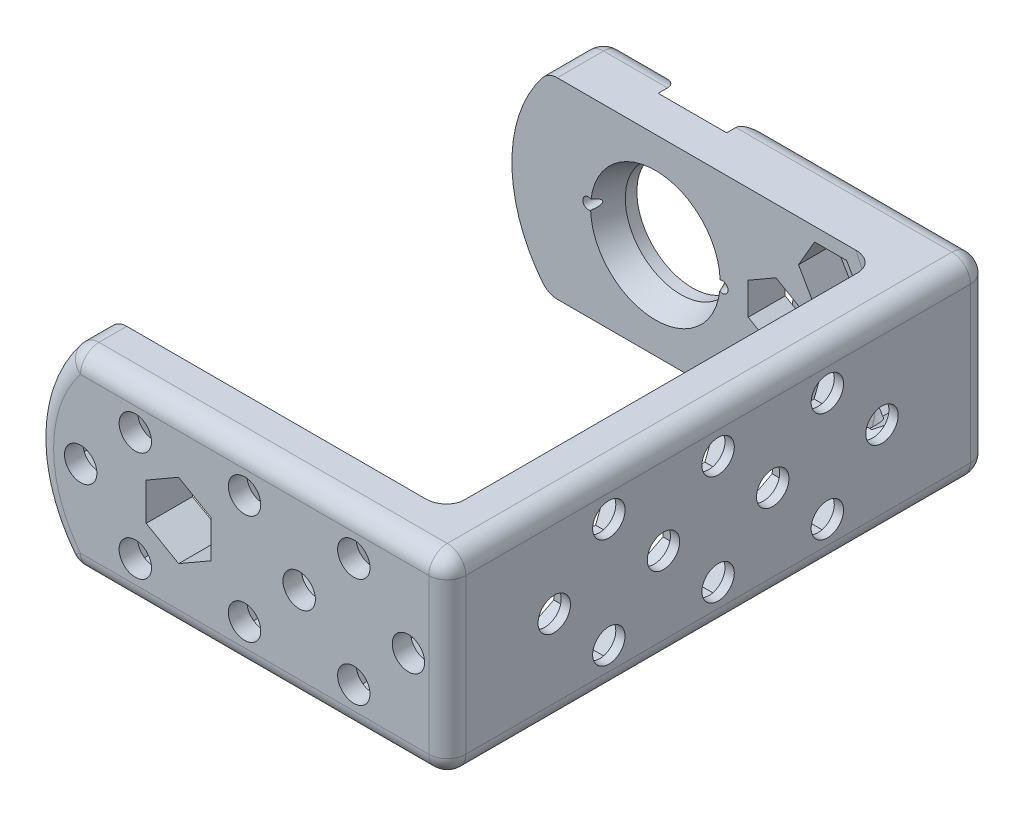
from build123d import *

# Parameters (mm, degrees)
SKETCH_1_R               = 6
EXTRUDE_1_DEPTH          = 5
EXTRUDE_4_DEPTH          = 2
EXTRUDE_START            = 5
EXTRUDE_5_DEPTH          = 46.5
EXTRUDE_7_DEPTH          = 5
FILLET_1_R               = 2
SKETCH_3_R               = 0.6
CUT_EXTRUDE_1_DEPTH      = 5
SKETCH_4_R               = 1.75
CUT_EXTRUDE_2_DEPTH      = 73.677365959
CUT_EXTRUDE_START        = -6
SKETCH_4_5_R             = 1.75
CUT_EXTRUDE_4_DEPTH      = 5
SKETCH_5_R               = 1.75
CUT_EXTRUDE_5_DEPTH      = 5
CUT_EXTRUDE_START_2      = -5
SKETCH_5_4_R             = 1.75
CUT_EXTRUDE_6_DEPTH      = 3
CUT_EXTRUDE_6_DEPTH_BACK = 3
SKETCH_6_R               = 1.75
CUT_EXTRUDE_7_DEPTH      = 7
CUT_EXTRUDE_START_3      = -7
CUT_EXTRUDE_8_DEPTH      = 4
CUT_EXTRUDE_8_DEPTH_BACK = 3
CUT_EXTRUDE_START_4      = -4
SKETCH_4_7_R             = 1.75
CUT_EXTRUDE_9_DEPTH      = 3
SKETCH_7_R               = 7
CUT_EXTRUDE_10_DEPTH     = 3
CUT_EXTRUDE_10_DRAFT     = -20
SKETCH_1_9_R             = 6
CUT_EXTRUDE_11_DEPTH     = 1


with BuildPart() as part:
    # Эскиз1 → Бобышка-Вытянуть1 (new body)
    with BuildSketch(Plane.XY):
        with BuildLine():
            Line((-10.599372336, -10.360819702), (27.024183719, -10.360819702))
            ThreePointArc((27.024183719, -10.360819702), (28.438397281, -9.775033264), (29.024183719, -8.360819702))
            Line((29.024183719, -8.360819702), (29.024183719, 8.360819702))
            ThreePointArc((29.024183719, 8.360819702), (28.438397281, 9.775033264), (27.024183719, 10.360819702))
            Line((27.024183719, 10.360819702), (-10.599372336, 10.360819702))
            ThreePointArc((-10.599372336, 10.360819702), (-11.471931815, 10.160441872), (-12.169649719, 9.599459658))
            ThreePointArc((-12.169649719, 9.599459658), (-15.5, 0), (-12.169649719, -9.599459658))
            ThreePointArc((-12.169649719, -9.599459658), (-11.471931815, -10.160441872), (-10.599372336, -10.360819702))
        make_face()
        Circle(SKETCH_1_R, mode=Mode.SUBTRACT)
    extrude(amount=EXTRUDE_1_DEPTH)

    # Эскиз1<5> → Бобышка-Вытянуть4 (add)
    with BuildSketch(Plane.XY):
        with BuildLine():
            Line((-10.599372336, -10.360819702), (-3.695052788, -10.360819702))
            ThreePointArc((-3.695052788, -10.360819702), (-11, 0), (-3.695052788, 10.360819702))
            Line((-3.695052788, 10.360819702), (-10.599372336, 10.360819702))
            ThreePointArc((-10.599372336, 10.360819702), (-11.471931815, 10.160441872), (-12.169649719, 9.599459658))
            ThreePointArc((-12.169649719, 9.599459658), (-15.5, 0), (-12.169649719, -9.599459658))
            ThreePointArc((-12.169649719, -9.599459658), (-11.471931815, -10.160441872), (-10.599372336, -10.360819702))
        make_face()
        with BuildLine():
            Line((3.695052788, -10.360819702), (23.872820389, -10.360819702))
            ThreePointArc((23.872820389, -10.360819702), (26.024183719, 0), (23.872820389, 10.360819702))
            Line((23.872820389, 10.360819702), (3.695052788, 10.360819702))
            ThreePointArc((3.695052788, 10.360819702), (8.990149628, 6.338549492), (11, 0))
            ThreePointArc((11, 0), (8.990149628, -6.338549492), (3.695052788, -10.360819702))
        make_face()
        with BuildLine():
            ThreePointArc((23.872820389, 10.360819702), (26.024183719, 0), (23.872820389, -10.360819702))
            Line((23.872820389, -10.360819702), (27.024183719, -10.360819702))
            ThreePointArc((27.024183719, -10.360819702), (28.438397281, -9.775033264), (29.024183719, -8.360819702))
            Line((29.024183719, -8.360819702), (29.024183719, 8.360819702))
            ThreePointArc((29.024183719, 8.360819702), (28.438397281, 9.775033264), (27.024183719, 10.360819702))
            Line((27.024183719, 10.360819702), (23.872820389, 10.360819702))
        make_face()
    extrude(amount=-EXTRUDE_4_DEPTH)

    # Эскиз1<7> → Бобышка-Вытянуть5 (add)
    with BuildSketch(Plane.XY.offset(EXTRUDE_START)):
        with BuildLine():
            ThreePointArc((23.872820389, 10.360819702), (26.024183719, 0), (23.872820389, -10.360819702))
            Line((23.872820389, -10.360819702), (27.024183719, -10.360819702))
            ThreePointArc((27.024183719, -10.360819702), (28.438397281, -9.775033264), (29.024183719, -8.360819702))
            Line((29.024183719, -8.360819702), (29.024183719, 8.360819702))
            ThreePointArc((29.024183719, 8.360819702), (28.438397281, 9.775033264), (27.024183719, 10.360819702))
            Line((27.024183719, 10.360819702), (23.872820389, 10.360819702))
        make_face()
    extrude(amount=EXTRUDE_5_DEPTH)

    # Эскиз2 → Бобышка-Вытянуть7 (add)
    with BuildSketch(Plane.XY.offset(51.5)):
        with BuildLine():
            Line((-10.599372336, -10.360819702), (27.024183719, -10.360819702))
            ThreePointArc((27.024183719, -10.360819702), (28.438397281, -9.775033264), (29.024183719, -8.360819702))
            Line((29.024183719, -8.360819702), (29.024183719, 8.360819702))
            ThreePointArc((29.024183719, 8.360819702), (28.438397281, 9.775033264), (27.024183719, 10.360819702))
            Line((27.024183719, 10.360819702), (-10.599372336, 10.360819702))
            ThreePointArc((-10.599372336, 10.360819702), (-11.471931815, 10.160441872), (-12.169649719, 9.599459658))
            ThreePointArc((-12.169649719, 9.599459658), (-15.5, 0), (-12.169649719, -9.599459658))
            ThreePointArc((-12.169649719, -9.599459658), (-11.471931815, -10.160441872), (-10.599372336, -10.360819702))
        make_face()
        Polygon((-3.5, -2.020725942), (0, -4.041451884), (3.5, -2.020725942), (3.5, 2.020725942), (0, 4.041451884), (-3.5, 2.020725942), align=None, mode=Mode.SUBTRACT)
    extrude(amount=EXTRUDE_7_DEPTH)

    # Скругление1
    fillet_1_edges = [part.edges().sort_by_distance(p)[0] for p in [
        (-7.147212562, -10.360819702, -2),
        (-11.471931815, -10.160441872, -2),
        (-7.147212562, 10.360819702, -2),
        (-11.471931815, 10.160441872, -2),
        (15.359618254, 10.360819702, -2),
        (28.438397281, 9.775033264, -2),
        (29.024183719, 0, -2),
        (15.359618254, -10.360819702, -2),
        (-11.471931815, -10.160441872, 56.5),
        (-15.5, 0, 56.5),
        (-11.471931815, 10.160441872, 56.5),
        (-15.5, 0, -2),
        (28.438397281, -9.775033264, -2),
        (26.024183719, 0, 5),
        (26.024183719, 0, 51.5),
        (8.212405691, -10.360819702, 56.5),
        (28.438397281, -9.775033264, 56.5),
        (29.024183719, 0, 56.5),
        (28.438397281, 9.775033264, 56.5),
        (8.212405691, 10.360819702, 56.5),
    ]]
    fillet(fillet_1_edges, radius=FILLET_1_R)

    # Эскиз3 → Вырез-Вытянуть1 (cut)
    with BuildSketch(Plane(origin=(0, 0, 0), x_dir=(-1, 0, 0), z_dir=(0, 0, -1))):
        with Locations((-7.243894835, -0.297468697)):
            Circle(SKETCH_3_R)
        with Locations((7.243894835, 0.297468697)):
            Circle(SKETCH_3_R)
    extrude(amount=-CUT_EXTRUDE_1_DEPTH, mode=Mode.SUBTRACT)

    # Эскиз4 → Вырез-Вытянуть2 (cut, through all)
    with BuildSketch(Plane(origin=(29.024183719, 0, 0), x_dir=(0, 0, -1), z_dir=(1, 0, 0))):
        with Locations((-21.350790023, 0)):
            Circle(SKETCH_4_R)
        with Locations((-27.25, 5.899209977)):
            Circle(SKETCH_4_R)
        with Locations((-33.149209977, 0)):
            Circle(SKETCH_4_R)
        with Locations((-44.949209977, 0)):
            Circle(SKETCH_4_R)
        with Locations((-39.05, -5.899209977)):
            Circle(SKETCH_4_R)
        with Locations((-39.05, 5.899209977)):
            Circle(SKETCH_4_R)
        with Locations((-15.45, -5.899209977)):
            Circle(SKETCH_4_R)
        with Locations((-9.550790023, 0)):
            Circle(SKETCH_4_R)
        with Locations((-15.45, 5.899209977)):
            Circle(SKETCH_4_R)
        with Locations((-27.25, -5.899209977)):
            Circle(SKETCH_4_R)
    extrude(amount=-CUT_EXTRUDE_2_DEPTH, mode=Mode.SUBTRACT)

    # Эскиз4<5> → Вырез-Вытянуть4 (cut)
    with BuildSketch(Plane(origin=(29.024183719, 0, 0), x_dir=(0, 0, -1), z_dir=(1, 0, 0)).offset(CUT_EXTRUDE_START)):
        Polygon((-41.092890578, -8.360819702), (-37.007109422, -8.360819702), (-35.585898385, -5.899209977), (-37.317949192, -2.899209977), (-40.782050808, -2.899209977), (-42.514101615, -5.899209977), align=None)
        with Locations((-39.05, -5.899209977)):
            Circle(SKETCH_4_5_R, mode=Mode.SUBTRACT)
        Polygon((-47.949209977, -1.732050808), (-44.949209977, -3.464101615), (-41.949209977, -1.732050808), (-41.949209977, 1.732050808), (-44.949209977, 3.464101615), (-47.949209977, 1.732050808), align=None)
        with Locations((-44.949209977, 0)):
            Circle(SKETCH_4_5_R, mode=Mode.SUBTRACT)
        Polygon((-35.585898385, 5.899209977), (-37.007109422, 8.360819702), (-41.092890578, 8.360819702), (-42.514101615, 5.899209977), (-40.782050808, 2.899209977), (-37.317949192, 2.899209977), align=None)
        with Locations((-39.05, 5.899209977)):
            Circle(SKETCH_4_5_R, mode=Mode.SUBTRACT)
        Polygon((-36.149209977, -1.732050808), (-33.149209977, -3.464101615), (-30.149209977, -1.732050808), (-30.149209977, 1.732050808), (-33.149209977, 3.464101615), (-36.149209977, 1.732050808), align=None)
        with Locations((-33.149209977, 0)):
            Circle(SKETCH_4_5_R, mode=Mode.SUBTRACT)
        Polygon((-30.714101615, 5.899209977), (-28.982050808, 2.899209977), (-25.517949192, 2.899209977), (-23.785898385, 5.899209977), (-25.207109422, 8.360819702), (-29.292890578, 8.360819702), align=None)
        with Locations((-27.25, 5.899209977)):
            Circle(SKETCH_4_5_R, mode=Mode.SUBTRACT)
        Polygon((-23.785898385, -5.899209977), (-25.517949192, -2.899209977), (-28.982050808, -2.899209977), (-30.714101615, -5.899209977), (-29.292890578, -8.360819702), (-25.207109422, -8.360819702), align=None)
        with Locations((-27.25, -5.899209977)):
            Circle(SKETCH_4_5_R, mode=Mode.SUBTRACT)
        Polygon((-18.350790023, 1.732050808), (-21.350790023, 3.464101615), (-24.350790023, 1.732050808), (-24.350790023, -1.732050808), (-21.350790023, -3.464101615), (-18.350790023, -1.732050808), align=None)
        with Locations((-21.350790023, 0)):
            Circle(SKETCH_4_5_R, mode=Mode.SUBTRACT)
        Polygon((-13.407109422, 8.360819702), (-17.492890578, 8.360819702), (-18.914101615, 5.899209977), (-17.182050808, 2.899209977), (-13.717949192, 2.899209977), (-11.985898385, 5.899209977), align=None)
        with Locations((-15.45, 5.899209977)):
            Circle(SKETCH_4_5_R, mode=Mode.SUBTRACT)
        Polygon((-18.914101615, -5.899209977), (-17.492890578, -8.360819702), (-13.407109422, -8.360819702), (-11.985898385, -5.899209977), (-13.717949192, -2.899209977), (-17.182050808, -2.899209977), align=None)
        with Locations((-15.45, -5.899209977)):
            Circle(SKETCH_4_5_R, mode=Mode.SUBTRACT)
        Polygon((-25.517949192, -8.899209977), (-25.207109422, -8.360819702), (-29.292890578, -8.360819702), (-28.982050808, -8.899209977), align=None)
        Polygon((-13.407109422, -8.360819702), (-17.492890578, -8.360819702), (-17.182050808, -8.899209977), (-13.717949192, -8.899209977), align=None)
        Polygon((-17.182050808, 8.899209977), (-17.492890578, 8.360819702), (-13.407109422, 8.360819702), (-13.717949192, 8.899209977), align=None)
        Polygon((-28.982050808, 8.899209977), (-29.292890578, 8.360819702), (-25.207109422, 8.360819702), (-25.517949192, 8.899209977), align=None)
        Polygon((-41.092890578, 8.360819702), (-37.007109422, 8.360819702), (-37.317949192, 8.899209977), (-40.782050808, 8.899209977), align=None)
        Polygon((-37.317949192, -8.899209977), (-37.007109422, -8.360819702), (-41.092890578, -8.360819702), (-40.782050808, -8.899209977), align=None)
    extrude(amount=CUT_EXTRUDE_4_DEPTH, mode=Mode.SUBTRACT)

    # Эскиз5 → Вырез-Вытянуть5 (cut)
    with BuildSketch(Plane.XY.offset(56.5)):
        with Locations((-10.575816281, 0)):
            Circle(SKETCH_5_R)
        with Locations((-4.675816281, -5.9)):
            Circle(SKETCH_5_R)
        with Locations((7.124183719, -5.9)):
            Circle(SKETCH_5_R)
        with Locations((7.124183719, 5.9)):
            Circle(SKETCH_5_R)
        with Locations((13.024183719, 0)):
            Circle(SKETCH_5_R)
        with Locations((18.924183719, 5.9)):
            Circle(SKETCH_5_R)
        with Locations((18.924183719, -5.9)):
            Circle(SKETCH_5_R)
        with Locations((-4.675816281, 5.9)):
            Circle(SKETCH_5_R)
        with Locations((24.824183719, 0)):
            Circle(SKETCH_5_R)
    extrude(amount=-CUT_EXTRUDE_5_DEPTH, mode=Mode.SUBTRACT)

    # Эскиз5<4> → Вырез-Вытянуть6 (cut, two sides)
    with BuildSketch(Plane.XY.offset(56.5).offset(CUT_EXTRUDE_START_2)) as cut_extrude_6_sk:
        Polygon((13.024183719, -3.464101615), (16.024183719, -1.732050808), (16.024183719, 1.732050808), (13.024183719, 3.464101615), (10.024183719, 1.732050808), (10.024183719, -1.732050808), align=None)
        with Locations((13.024183719, 0)):
            Circle(SKETCH_5_4_R, mode=Mode.SUBTRACT)
        Polygon((22.388285334, -5.9), (20.656234526, -2.9), (17.192132911, -2.9), (15.460082104, -5.9), (16.880837021, -8.360819702), (20.967530417, -8.360819702), align=None)
        with Locations((18.924183719, -5.9)):
            Circle(SKETCH_5_4_R, mode=Mode.SUBTRACT)
        Polygon((5.080837021, -8.360819702), (9.167530417, -8.360819702), (10.588285334, -5.9), (8.856234526, -2.9), (5.392132911, -2.9), (3.660082104, -5.9), align=None)
        with Locations((7.124183719, -5.9)):
            Circle(SKETCH_5_4_R, mode=Mode.SUBTRACT)
        Polygon((27.824183719, 1.732050808), (24.824183719, 3.464101615), (21.824183719, 1.732050808), (21.824183719, -1.732050808), (24.824183719, -3.464101615), (27.824183719, -1.732050808), align=None)
        Polygon((-6.719162979, -8.360819702), (-2.632469583, -8.360819702), (-1.211714666, -5.9), (-2.943765474, -2.9), (-6.407867089, -2.9), (-8.139917896, -5.9), align=None)
        with Locations((-4.675816281, -5.9)):
            Circle(SKETCH_5_4_R, mode=Mode.SUBTRACT)
        Polygon((17.192132911, 8.9), (15.460082104, 5.9), (17.192132911, 2.9), (20.656234526, 2.9), (22.388285334, 5.9), (20.656234526, 8.9), align=None)
        with Locations((18.924183719, 5.9)):
            Circle(SKETCH_5_4_R, mode=Mode.SUBTRACT)
        with BuildLine():
            ThreePointArc((-13.37273698, 1.849298697), (-13.5, 0), (-13.37273698, -1.849298697))
            Line((-13.37273698, -1.849298697), (-10.575816281, -3.464101615))
            Line((-10.575816281, -3.464101615), (-7.575816281, -1.732050808))
            Line((-7.575816281, -1.732050808), (-7.575816281, 1.732050808))
            Line((-7.575816281, 1.732050808), (-10.575816281, 3.464101615))
            Line((-10.575816281, 3.464101615), (-13.37273698, 1.849298697))
        make_face()
        with Locations((-10.575816281, 0)):
            Circle(SKETCH_5_4_R, mode=Mode.SUBTRACT)
        Polygon((10.588285334, 5.9), (9.167530417, 8.360819702), (5.080837021, 8.360819702), (3.660082104, 5.9), (5.392132911, 2.9), (8.856234526, 2.9), align=None)
        with Locations((7.124183719, 5.9)):
            Circle(SKETCH_5_4_R, mode=Mode.SUBTRACT)
        Polygon((-1.211714666, 5.9), (-2.632469583, 8.360819702), (-6.719162979, 8.360819702), (-8.139917896, 5.9), (-6.407867089, 2.9), (-2.943765474, 2.9), align=None)
        with Locations((-4.675816281, 5.9)):
            Circle(SKETCH_5_4_R, mode=Mode.SUBTRACT)
    extrude(amount=CUT_EXTRUDE_6_DEPTH, mode=Mode.SUBTRACT)
    extrude(cut_extrude_6_sk.sketch, amount=-CUT_EXTRUDE_6_DEPTH_BACK, mode=Mode.SUBTRACT)

    # Эскиз6 → Вырез-Вытянуть7 (cut)
    with BuildSketch(Plane(origin=(0, 0, -2), x_dir=(-1, 0, 0), z_dir=(0, 0, -1))):
        with Locations(Location((-18.924183719, 5.9, 0), (0, 0, 180))):
            Circle(SKETCH_6_R)
        with Locations(Location((-13.024183719, 0, 0), (0, 0, 180))):
            Circle(SKETCH_6_R)
        with Locations(Location((-18.924183719, -5.9, 0), (0, 0, 180))):
            Circle(SKETCH_6_R)
        with Locations(Location((-24.824183719, 0, 0), (0, 0, 180))):
            Circle(SKETCH_6_R)
    extrude(amount=-CUT_EXTRUDE_7_DEPTH, mode=Mode.SUBTRACT)

    # Эскиз6<4> → Вырез-Вытянуть8 (cut, two sides)
    with BuildSketch(Plane(origin=(0, 0, -2), x_dir=(-1, 0, 0), z_dir=(0, 0, -1)).offset(CUT_EXTRUDE_START_3)) as cut_extrude_8_sk:
        Polygon((-10.024183719, 1.732050808), (-13.024183719, 3.464101615), (-16.024183719, 1.732050808), (-16.024183719, -1.732050808), (-13.024183719, -3.464101615), (-10.024183719, -1.732050808), align=None)
        Polygon((-17.192132911, 8.9), (-20.656234526, 8.9), (-22.388285334, 5.9), (-20.656234526, 2.9), (-17.192132911, 2.9), (-15.460082104, 5.9), align=None)
        Polygon((-24.824183719, -3.464101615), (-21.824183719, -1.732050808), (-21.824183719, 1.732050808), (-24.824183719, 3.464101615), (-27.824183719, 1.732050808), (-27.824183719, -1.732050808), align=None)
        Polygon((-15.460082104, -5.9), (-17.192132911, -2.9), (-20.656234526, -2.9), (-22.388285334, -5.9), (-20.967530417, -8.360819702), (-16.880837021, -8.360819702), align=None)
    extrude(amount=CUT_EXTRUDE_8_DEPTH, mode=Mode.SUBTRACT)
    extrude(cut_extrude_8_sk.sketch, amount=-CUT_EXTRUDE_8_DEPTH_BACK, mode=Mode.SUBTRACT)

    # Эскиз4<7> → Вырез-Вытянуть9 (cut)
    with BuildSketch(Plane(origin=(29.024183719, 0, 0), x_dir=(0, 0, -1), z_dir=(1, 0, 0)).offset(CUT_EXTRUDE_START_4)):
        Polygon((-6.550790023, 1.732050808), (-9.550790023, 3.464101615), (-12.550790023, 1.732050808), (-12.550790023, -1.732050808), (-9.550790023, -3.464101615), (-6.550790023, -1.732050808), align=None)
        with Locations((-9.550790023, 0)):
            Circle(SKETCH_4_7_R, mode=Mode.SUBTRACT)
    extrude(amount=CUT_EXTRUDE_9_DEPTH, mode=Mode.SUBTRACT)


with BuildPart() as cut_extrude_10_tool:
    # Эскиз7 → Вырез-Вытянуть10 (with draft: the straight prism first)
    with BuildSketch(Plane.XY.offset(5)):
        Circle(SKETCH_7_R)
    extrude(amount=-CUT_EXTRUDE_10_DEPTH)
    # Вырез-Вытянуть10: the draft: its side faces are tilted about the plane it starts from
    cut_extrude_10_sides = [cut_extrude_10_tool.faces().sort_by_distance(p)[0] for p in [
        (-7, 0, 3.5),
    ]]
    draft(cut_extrude_10_sides, Plane.XY.offset(5), CUT_EXTRUDE_10_DRAFT)


with BuildPart() as part_1:
    add(part.part)

    # Вырез-Вытянуть10: cut by cut_extrude_10_tool
    add(cut_extrude_10_tool.part, mode=Mode.SUBTRACT)

    # Эскиз1<9> → Вырез-Вытянуть11 (cut)
    with BuildSketch(Plane.XY):
        with BuildLine():
            Line((-3.695052788, -10.360819702), (3.695052788, -10.360819702))
            ThreePointArc((3.695052788, -10.360819702), (8.990149628, -6.338549492), (11, 0))
            ThreePointArc((11, 0), (8.990149628, 6.338549492), (3.695052788, 10.360819702))
            Line((3.695052788, 10.360819702), (-3.695052788, 10.360819702))
            ThreePointArc((-3.695052788, 10.360819702), (-11, 0), (-3.695052788, -10.360819702))
        make_face()
        Circle(SKETCH_1_9_R, mode=Mode.SUBTRACT)
    extrude(amount=CUT_EXTRUDE_11_DEPTH, mode=Mode.SUBTRACT)


solid = part_1.part
